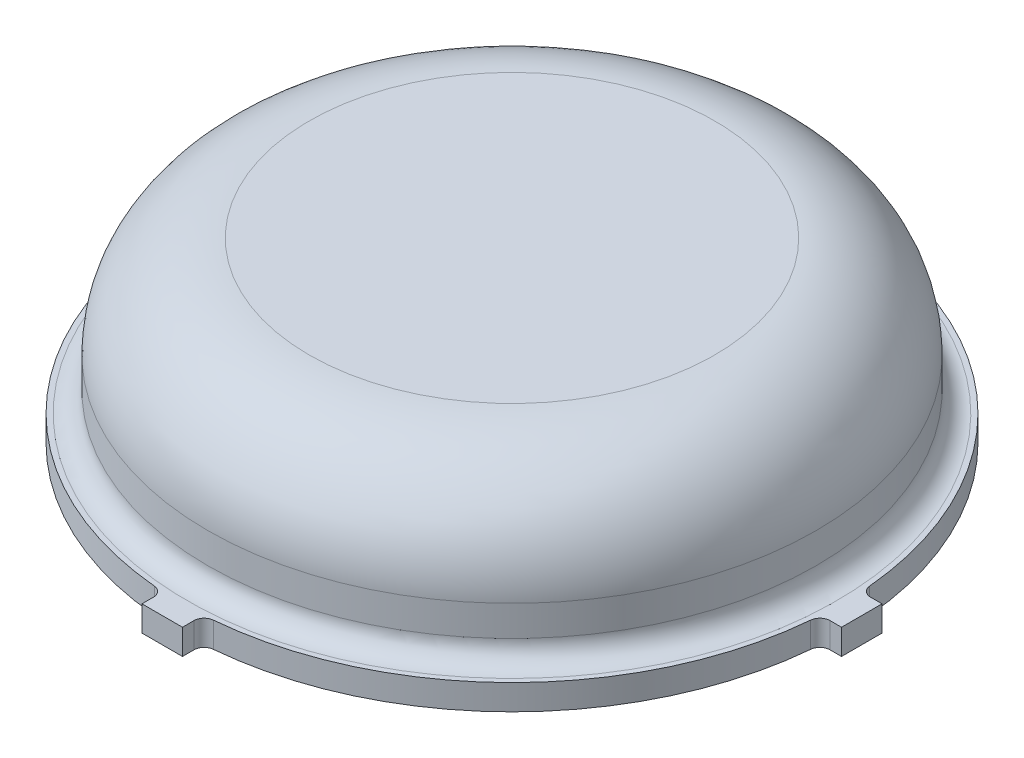
from build123d import *

# Parameters (mm, degrees)
SKETCH1_R            = 38.1
BOSS_EXTRUDE1_DEPTH  = 19.05
FILLET1_R            = 12.7
SKETCH2_R            = 41.275
BOSS_EXTRUDE2_DEPTH  = 3.175
SHELL2_T             = -2.54
FILLET2_R            = 2.54
SKETCH27_W           = 5.08
SKETCH27_H           = 5.08
BOSS_EXTRUDE12_DEPTH = 3.175
FILLET3_R            = 1.27
SKETCH28_R           = 38.735
SKETCH28_R_2         = 35.56
BOSS_EXTRUDE16_DEPTH = 0.635
SKETCH31_R           = 6
SKETCH31_R_2         = 4.5
BOSS_EXTRUDE17_DEPTH = 19.685
FILLET4_R            = 8.89
SKETCH32_R           = 6
BOSS_EXTRUDE18_DEPTH = 1.27
FILLET5_R            = 2.54


with BuildPart() as part:
    # Sketch1 → Boss-Extrude1 (new body)
    with BuildSketch(Plane(origin=(0, 0, 0), x_dir=(1, 0, 0), z_dir=(0, 1, 0))):
        with Locations(Location((0, 0, 0), (0, 0, 90))):
            Circle(SKETCH1_R)
    extrude(amount=BOSS_EXTRUDE1_DEPTH)

    # Fillet1
    fillet1_edges = [part.edges().sort_by_distance(p)[0] for p in [
        (0, 19.05, 38.1),
    ]]
    fillet(fillet1_edges, radius=FILLET1_R)

    # Sketch2 → Boss-Extrude2 (add)
    with BuildSketch(Plane.XZ):
        with Locations(Location((0, 0, 0), (0, 0, 270))):
            Circle(SKETCH2_R)
    extrude(amount=BOSS_EXTRUDE2_DEPTH)

    # Shell2
    shell2_openings = [part.faces().sort_by_distance(p)[0] for p in [
        (0, -3.175, 0),
    ]]
    offset(amount=SHELL2_T, openings=shell2_openings, kind=Kind.INTERSECTION)

    # Fillet2
    fillet2_edges = [part.edges().sort_by_distance(p)[0] for p in [
        (0, 0, 38.1),
    ]]
    fillet(fillet2_edges, radius=FILLET2_R)

    # Sketch27 → Boss-Extrude12 (add)
    with BuildSketch(Plane.XZ.offset(3.175)):
        with Locations((-41.275, 0)):
            Rectangle(SKETCH27_W, SKETCH27_H)
        with Locations((0, 41.275)):
            Rectangle(SKETCH27_W, SKETCH27_H)
        with Locations((41.275, 0)):
            Rectangle(SKETCH27_W, SKETCH27_H)
        with Locations((0, -41.275)):
            Rectangle(SKETCH27_W, SKETCH27_H)
    extrude(amount=-BOSS_EXTRUDE12_DEPTH)

    # Fillet3
    fillet3_edges = [part.edges().sort_by_distance(p)[0] for p in [
        (-2.54, -1.5875, 41.196772022),
        (2.54, -1.5875, 41.196772022),
        (41.196772022, -1.5875, 2.54),
        (41.196772022, -1.5875, -2.54),
        (2.54, -1.5875, -41.196772022),
        (-2.54, -1.5875, -41.196772022),
        (-41.196772022, -1.5875, -2.54),
        (-41.196772022, -1.5875, 2.54),
    ]]
    fillet(fillet3_edges, radius=FILLET3_R)

    # Sketch28 → Boss-Extrude16 (add)
    with BuildSketch(Plane.XZ.offset(2.54)):
        Circle(SKETCH28_R)
        with Locations(Location((0, 0, 0), (0, 0, 270))):
            Circle(SKETCH28_R_2, mode=Mode.SUBTRACT)
    extrude(amount=BOSS_EXTRUDE16_DEPTH)

    # Sketch31 → Boss-Extrude17 (add)
    with BuildSketch(Plane.XZ.offset(-16.51)):
        with Locations(Location((0, 0, 0), (0, 0, 90))):
            Circle(SKETCH31_R)
        with Locations(Location((0, 0, 0), (0, 0, 90))):
            Circle(SKETCH31_R_2, mode=Mode.SUBTRACT)
    extrude(amount=BOSS_EXTRUDE17_DEPTH)

    # Fillet4
    fillet4_edges = [part.edges().sort_by_distance(p)[0] for p in [
        (0, 16.51, -6),
    ]]
    fillet(fillet4_edges, radius=FILLET4_R)

    # Sketch32 → Boss-Extrude18 (add)
    with BuildSketch(Plane.XZ.offset(3.175)):
        with Locations(Location((0, 0, 0), (0, 0, 90))):
            Circle(SKETCH32_R)
    extrude(amount=-BOSS_EXTRUDE18_DEPTH)

    # Fillet5
    fillet5_edges = [part.edges().sort_by_distance(p)[0] for p in [
        (0, -1.905, -4.5),
    ]]
    fillet(fillet5_edges, radius=FILLET5_R)


solid = part.part
